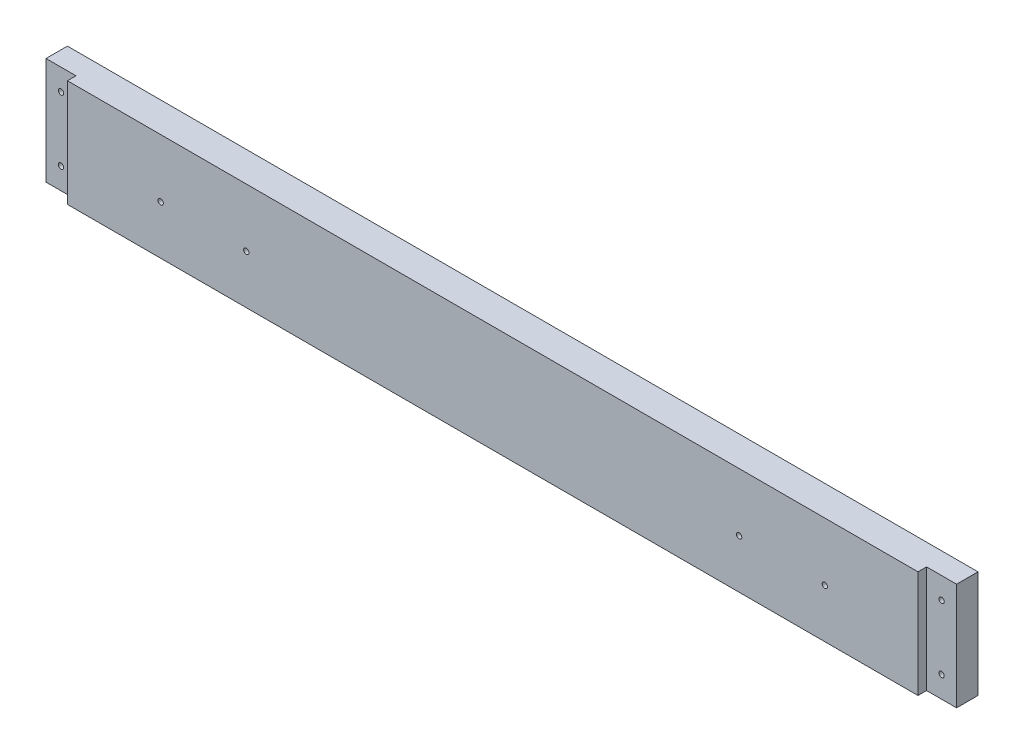
from build123d import *

# Parameters (mm, degrees)
PEDOUTLINE_W               = 539.75
PEDOUTLINE_H               = 63.5
PEDOUTLINE_THICKNESS_DEPTH = 17.78
PEDLEDGECUTS_W             = 17.78
PEDLEDGECUTS_H             = 63.5
PEDLEDGECUTS_DEPTH_DEPTH   = 5.08
SKETCH4_R                  = 1.5875
CUT_EXTRUDE2_DEPTH         = 17.78
SKETCH5_R                  = 1.5875
CUT_EXTRUDE3_DEPTH         = 17.78


with BuildPart() as part:
    # PedOutline → PedOutline_Thickness (new body)
    with BuildSketch(Plane.XY):
        with Locations((11108.266666666, -5688.0125)):
            Rectangle(PEDOUTLINE_W, PEDOUTLINE_H)
    extrude(amount=-PEDOUTLINE_THICKNESS_DEPTH)

    # PedLedgeCuts → PedLedgeCuts_Depth (cut)
    with BuildSketch(Plane.XY):
        with Locations((11369.251666666, -5688.0125)):
            Rectangle(PEDLEDGECUTS_W, PEDLEDGECUTS_H)
        with Locations((10847.281666666, -5688.0125)):
            Rectangle(PEDLEDGECUTS_W, PEDLEDGECUTS_H)
    extrude(amount=-PEDLEDGECUTS_DEPTH_DEPTH, mode=Mode.SUBTRACT)

    # Sketch4 → Cut-Extrude2 (cut)
    with BuildSketch(Plane.XY):
        with Locations((10847.281666666, -5668.9625)):
            Circle(SKETCH4_R)
        with Locations((10847.281666666, -5707.0625)):
            Circle(SKETCH4_R)
        with Locations((11369.251666666, -5707.0625)):
            Circle(SKETCH4_R)
        with Locations((11369.251666666, -5668.9625)):
            Circle(SKETCH4_R)
    extrude(amount=-CUT_EXTRUDE2_DEPTH, mode=Mode.SUBTRACT)

    # Sketch5 → Cut-Extrude3 (cut)
    with BuildSketch(Plane(origin=(0, 0, -17.78), x_dir=(-1, 0, 0), z_dir=(0, 0, -1))):
        with Locations((-10911.416666665, -5690.78745)):
            Circle(SKETCH5_R)
        with Locations((-10962.216666665, -5690.78745)):
            Circle(SKETCH5_R)
        with Locations((-11254.316666665, -5690.78745)):
            Circle(SKETCH5_R)
        with Locations((-11305.116666665, -5690.78745)):
            Circle(SKETCH5_R)
    extrude(amount=-CUT_EXTRUDE3_DEPTH, mode=Mode.SUBTRACT)


solid = part.part
